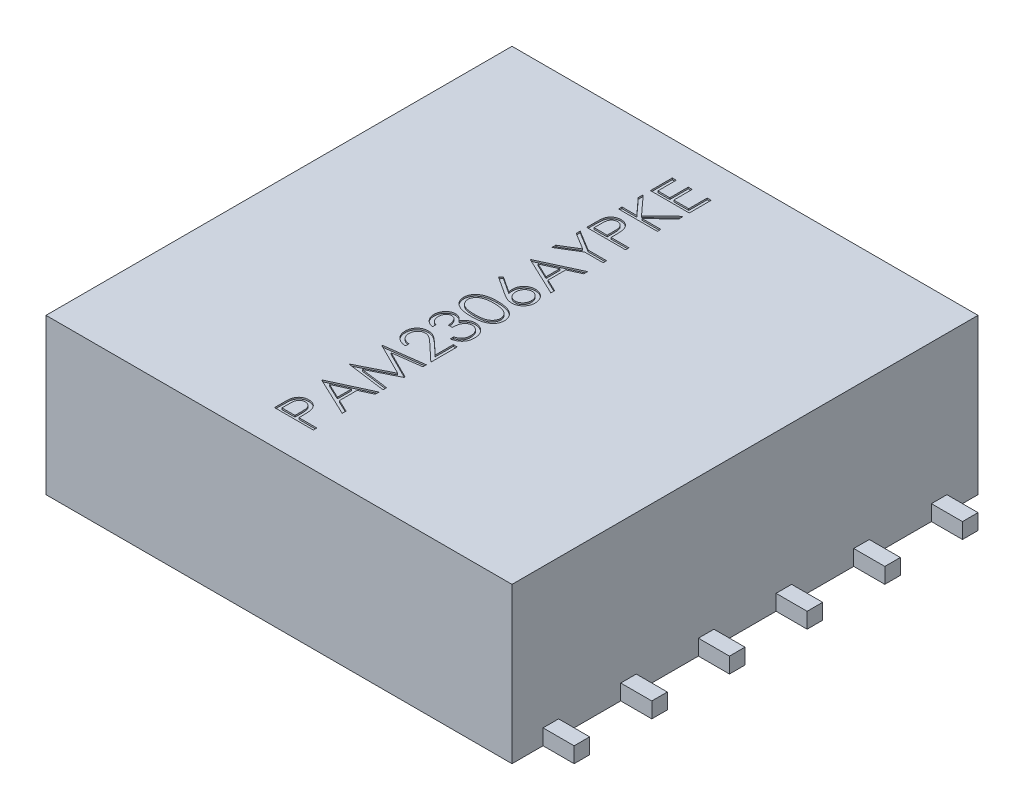
from build123d import *

# Parameters (mm, degrees)
BASES_W                = 3
BASES_H                = 3
BASE_DEPTH             = 1
SOLDERCONNECTIONS_W    = 0.2
SOLDERCONNECTIONS_H    = 0.1
SOLDERCONNECTION_DEPTH = 0.1
SC_LP_COUNT            = 6
SC_LP_PITCH            = 0.5
SC_CP_COUNT            = 2
SC_CP_COPY_1_SKETCH_W  = 0.2
SC_CP_COPY_1_SKETCH_H  = 0.1
SC_CP_COPY_1_DEPTH     = 0.1
SC_CP_COPY_2_SKETCH_W  = 0.2
SC_CP_COPY_2_SKETCH_H  = 0.1
SC_CP_COPY_2_DEPTH     = 0.1
SC_CP_COPY_3_SKETCH_W  = 0.2
SC_CP_COPY_3_SKETCH_H  = 0.1
SC_CP_COPY_3_DEPTH     = 0.1
SC_CP_COPY_4_SKETCH_W  = 0.2
SC_CP_COPY_4_SKETCH_H  = 0.1
SC_CP_COPY_4_DEPTH     = 0.1
SC_CP_COPY_5_SKETCH_W  = 0.2
SC_CP_COPY_5_SKETCH_H  = 0.1
SC_CP_COPY_5_DEPTH     = 0.1
PARTNO_DEPTH           = 0.01


with BuildPart() as part:
    # BaseS → Base (new body)
    with BuildSketch(Plane(origin=(0, 0, 0), x_dir=(1, 0, 0), z_dir=(0, 1, 0))):
        Rectangle(BASES_W, BASES_H)
    extrude(amount=BASE_DEPTH)

    # SolderConnectionS → SolderConnection (add)
    with BuildSketch(Plane(origin=(0, 0, 0), x_dir=(1, 0, 0), z_dir=(0, 1, 0))):
        with Locations((1.6, -1.25)):
            Rectangle(SOLDERCONNECTIONS_W, SOLDERCONNECTIONS_H)
    solderconnection = extrude(amount=SOLDERCONNECTION_DEPTH)

    # SC LP: SolderConnection ×6
    with Locations(*[(0, 0, -i * SC_LP_PITCH) for i in range(1, SC_LP_COUNT)]):
        add(solderconnection)

    # SC CP: SolderConnection ×2 about axis
    sc_cp_axis = Axis((0, 0.84, 0), (0, -1, 0))
    for i in range(1, SC_CP_COUNT):
        add(solderconnection.rotate(sc_cp_axis, i * 360 / SC_CP_COUNT))

    # SC CP copy 1 sketch → SC CP copy 1 (add)
    with BuildSketch(Plane(origin=(0, 0, 0.5), x_dir=(-1, 0, 0), z_dir=(0, 1, 0))):
        with Locations((1.6, -1.25)):
            Rectangle(SC_CP_COPY_1_SKETCH_W, SC_CP_COPY_1_SKETCH_H)
    extrude(amount=SC_CP_COPY_1_DEPTH)

    # SC CP copy 2 sketch → SC CP copy 2 (add)
    with BuildSketch(Plane(origin=(0, 0, 1), x_dir=(-1, 0, 0), z_dir=(0, 1, 0))):
        with Locations((1.6, -1.25)):
            Rectangle(SC_CP_COPY_2_SKETCH_W, SC_CP_COPY_2_SKETCH_H)
    extrude(amount=SC_CP_COPY_2_DEPTH)

    # SC CP copy 3 sketch → SC CP copy 3 (add)
    with BuildSketch(Plane(origin=(0, 0, 1.5), x_dir=(-1, 0, 0), z_dir=(0, 1, 0))):
        with Locations((1.6, -1.25)):
            Rectangle(SC_CP_COPY_3_SKETCH_W, SC_CP_COPY_3_SKETCH_H)
    extrude(amount=SC_CP_COPY_3_DEPTH)

    # SC CP copy 4 sketch → SC CP copy 4 (add)
    with BuildSketch(Plane(origin=(0, 0, 2), x_dir=(-1, 0, 0), z_dir=(0, 1, 0))):
        with Locations((1.6, -1.25)):
            Rectangle(SC_CP_COPY_4_SKETCH_W, SC_CP_COPY_4_SKETCH_H)
    extrude(amount=SC_CP_COPY_4_DEPTH)

    # SC CP copy 5 sketch → SC CP copy 5 (add)
    with BuildSketch(Plane(origin=(0, 0, 2.5), x_dir=(-1, 0, 0), z_dir=(0, 1, 0))):
        with Locations((1.6, -1.25)):
            Rectangle(SC_CP_COPY_5_SKETCH_W, SC_CP_COPY_5_SKETCH_H)
    extrude(amount=SC_CP_COPY_5_DEPTH)

    # PartNoS → PartNo (cut)
    # profile 1 of 12: a face of its own
    with BuildSketch(Plane(origin=(0, 1, 0), x_dir=(1, 0, 0), z_dir=(0, 1, 0))):
        with BuildLine():
            Line((-0.25, -1.278846154), (-0.25, -1.229817708))
            add(Edge.make_bspline(
                [(-0.25, -1.229817708), (-0.249996293, -1.226445501), (-0.249989191, -1.219984201), (-0.249773852, -1.21071884), (-0.249486231, -1.202303859), (-0.249087524, -1.194757404), (-0.248616339, -1.188056254), (-0.247955479, -1.182230732), (-0.247265458, -1.17723505), (-0.246563929, -1.174241732), (-0.24624399, -1.172876603)],
                knots=[0, 0, 0, 0, 1.415646017, 2.712440637, 3.8905458, 4.950247383, 5.884950622, 6.709939814, 7.411656543, 8, 8, 8, 8], degree=3))
            add(Edge.make_bspline(
                [(-0.24624399, -1.172876603), (-0.245770975, -1.171148508), (-0.244836092, -1.167733039), (-0.242963951, -1.162811318), (-0.240742802, -1.15812971), (-0.238216195, -1.15366732), (-0.23525976, -1.149505424), (-0.232070175, -1.145505281), (-0.228441316, -1.141808097), (-0.224487638, -1.138363795), (-0.220259285, -1.135180321), (-0.215679435, -1.132505628), (-0.210884821, -1.13016696), (-0.205810279, -1.128252173), (-0.200450883, -1.126828258), (-0.194844721, -1.125771145), (-0.188985488, -1.125097091), (-0.184981158, -1.125032752), (-0.182942708, -1.125)],
                knots=[0, 0, 0, 0, 0.999549623, 1.97554611, 2.93413192, 3.889860808, 4.833293765, 5.780583482, 6.742559327, 7.719844669, 8.705620613, 9.691528643, 10.674968152, 11.680406189, 12.713313868, 13.765869198, 14.862690416, 16, 16, 16, 16], degree=3))
            add(Edge.make_bspline(
                [(-0.182942708, -1.125), (-0.180887153, -1.125030102), (-0.17686532, -1.125088998), (-0.170981549, -1.125795875), (-0.165358807, -1.126748032), (-0.160009561, -1.128212107), (-0.154965577, -1.130129655), (-0.150149775, -1.132379088), (-0.145644084, -1.135092197), (-0.141432147, -1.138209685), (-0.13751001, -1.141677656), (-0.133906096, -1.145481437), (-0.130641501, -1.149605672), (-0.127708905, -1.154037254), (-0.125176313, -1.158819386), (-0.122907934, -1.16387954), (-0.121002859, -1.169261698), (-0.120000711, -1.172986164), (-0.119491186, -1.174879808)],
                knots=[0, 0, 0, 0, 1.121902311, 2.195077645, 3.232258892, 4.234102512, 5.217864754, 6.176164875, 7.132989551, 8.084763148, 9.034132444, 9.988522005, 10.94243251, 11.903244335, 12.886203696, 13.894208494, 14.929344452, 16, 16, 16, 16], degree=3))
            add(Edge.make_bspline(
                [(-0.119491186, -1.174879808), (-0.119158364, -1.176446064), (-0.118428966, -1.179878605), (-0.117609142, -1.185531302), (-0.116936797, -1.192116061), (-0.11630936, -1.199610477), (-0.115976896, -1.208032027), (-0.11558653, -1.217361396), (-0.115402338, -1.227630158), (-0.115390694, -1.2347923), (-0.115384615, -1.238531651)],
                knots=[0, 0, 0, 0, 0.601372724, 1.317943291, 2.144091499, 3.08771165, 4.142394186, 5.309582461, 6.595334295, 8, 8, 8, 8], degree=3))
            Line((-0.115384615, -1.238531651), (-0.115384615, -1.256410256))
            Line((-0.115384615, -1.256410256), (0, -1.256410256))
            Line((0, -1.256410256), (0, -1.278846154))
            Line((0, -1.278846154), (-0.25, -1.278846154))
        make_face()
        with BuildLine():
            Line((-0.224358974, -1.256410256), (-0.141025641, -1.256410256))
            Line((-0.141025641, -1.256410256), (-0.14047476, -1.212640224))
            add(Edge.make_bspline(
                [(-0.14047476, -1.212640224), (-0.140473583, -1.210503072), (-0.140471311, -1.206377343), (-0.140756937, -1.200417813), (-0.141082265, -1.1948879), (-0.141574306, -1.189808398), (-0.142219293, -1.185161486), (-0.1430214, -1.180987301), (-0.143893417, -1.177223412), (-0.145350342, -1.172893786), (-0.147590513, -1.168027143), (-0.150851581, -1.162710708), (-0.15507614, -1.158239981), (-0.159812763, -1.154378327), (-0.165067871, -1.151253538), (-0.170720098, -1.149049124), (-0.176685707, -1.147691737), (-0.180765362, -1.147522212), (-0.182842548, -1.147435897)],
                knots=[0, 0, 0, 0, 1.160746174, 2.240796558, 3.240300023, 4.169675897, 5.012224395, 5.787635701, 6.478238024, 7.109103438, 8.265591281, 9.382545711, 10.479929969, 11.588830844, 12.694575677, 13.785760505, 14.872603606, 16, 16, 16, 16], degree=3))
            add(Edge.make_bspline(
                [(-0.182842548, -1.147435897), (-0.18485244, -1.147526087), (-0.188847856, -1.147705374), (-0.194703511, -1.149037922), (-0.200291665, -1.151277209), (-0.205504452, -1.154381059), (-0.210230653, -1.158148997), (-0.214343278, -1.162524935), (-0.217627308, -1.167520067), (-0.219828603, -1.172127959), (-0.221117383, -1.176254269), (-0.222048223, -1.179820684), (-0.2226901, -1.183868148), (-0.223304297, -1.188358204), (-0.223800077, -1.193285151), (-0.224144365, -1.198680303), (-0.224343744, -1.204525695), (-0.224353775, -1.208583574), (-0.224358974, -1.210687099)],
                knots=[0, 0, 0, 0, 1.120540835, 2.227496496, 3.330685923, 4.466139262, 5.598993257, 6.692710361, 7.80064471, 8.921224235, 9.527843361, 10.209888745, 10.975318552, 11.811557897, 12.738105936, 13.73658638, 14.826690375, 16, 16, 16, 16], degree=3))
            Line((-0.224358974, -1.210687099), (-0.224358974, -1.256410256))
        make_face(mode=Mode.SUBTRACT)
    # profile 2 of 12: a face of its own
    with BuildSketch(Plane(origin=(0, 1, 0), x_dir=(1, 0, 0), z_dir=(0, 1, 0))):
        Polygon((-0.25, -0.971153846), (0, -0.855769231), (0, -0.880158253), (-0.080128205, -0.917117388), (-0.080128205, -1.030448718), (0, -1.068459535), (0, -1.092948718), (-0.25, -0.974358974), align=None)
        Polygon((-0.201272035, -0.973006811), (-0.105769231, -1.018279247), (-0.105769231, -0.928936298), align=None, mode=Mode.SUBTRACT)
    # profile 3 of 12: a face of its own
    with BuildSketch(Plane(origin=(0, 1, 0), x_dir=(1, 0, 0), z_dir=(0, 1, 0))):
        Polygon((0, -0.830128205), (-0.25, -0.797125401), (-0.25, -0.793920272), (-0.044871795, -0.690705128), (-0.25, -0.587740385), (-0.25, -0.584485176), (0, -0.551282051), (0, -0.573818109), (-0.179887821, -0.59775641), (0, -0.688000801), (0, -0.693058894), (-0.180288462, -0.783653846), (0, -0.807542067), align=None)
    # profile 4 of 12: a face of its own
    with BuildSketch(Plane(origin=(0, 1, 0), x_dir=(1, 0, 0), z_dir=(0, 1, 0))):
        with BuildLine():
            Line((-0.173076923, -0.490384615), (-0.173076923, -0.512820513))
            add(Edge.make_bspline(
                [(-0.173076923, -0.512820513), (-0.176053415, -0.512674288), (-0.181899166, -0.512387105), (-0.190422302, -0.511042227), (-0.198569074, -0.509117879), (-0.206274067, -0.506397061), (-0.213605411, -0.503018041), (-0.220533983, -0.498965896), (-0.227033354, -0.494166335), (-0.233043271, -0.488722997), (-0.238556669, -0.482810952), (-0.243317758, -0.476431956), (-0.247340449, -0.46972874), (-0.250703395, -0.46272164), (-0.253227669, -0.4553316), (-0.255100644, -0.447625681), (-0.256227526, -0.439570029), (-0.256348653, -0.434081456), (-0.256410256, -0.431290064)],
                knots=[0, 0, 0, 0, 1.10065271, 2.161652631, 3.183658789, 4.190468796, 5.17591951, 6.163126047, 7.15150782, 8.156236427, 9.156009102, 10.134482811, 11.092018607, 12.041330605, 13.001268258, 13.972401359, 14.968799086, 16, 16, 16, 16], degree=3))
            add(Edge.make_bspline(
                [(-0.256410256, -0.431290064), (-0.256346602, -0.42854858), (-0.256221523, -0.423161662), (-0.255131225, -0.415302819), (-0.25346044, -0.407803597), (-0.250984601, -0.400748987), (-0.247877964, -0.394066586), (-0.244014453, -0.387839136), (-0.239576879, -0.381916049), (-0.234342541, -0.37658802), (-0.22875749, -0.371693582), (-0.222792703, -0.367474873), (-0.216624929, -0.363841688), (-0.210205989, -0.360868039), (-0.20351498, -0.358613881), (-0.196616052, -0.356943766), (-0.189429585, -0.355989038), (-0.184564691, -0.355843317), (-0.182091346, -0.355769231)],
                knots=[0, 0, 0, 0, 1.111674182, 2.184400057, 3.212814286, 4.223731311, 5.211378316, 6.196328225, 7.191884489, 8.207283132, 9.220262353, 10.201199469, 11.166417575, 12.120932471, 13.06540007, 14.026332106, 14.996573967, 16, 16, 16, 16], degree=3))
            add(Edge.make_bspline(
                [(-0.182091346, -0.355769231), (-0.178609359, -0.35589018), (-0.17170649, -0.356129956), (-0.161562549, -0.358180955), (-0.151734532, -0.361384383), (-0.143824455, -0.365240996), (-0.137451237, -0.369132649), (-0.132201254, -0.372636087), (-0.126549921, -0.376760765), (-0.120474365, -0.381471444), (-0.114054149, -0.386849248), (-0.107158286, -0.392754463), (-0.099914283, -0.399339594), (-0.094963308, -0.403957353), (-0.092397837, -0.40635016)],
                knots=[0, 0, 0, 0, 1.184416499, 2.348048165, 3.509039915, 4.696071444, 5.333504901, 6.05069495, 6.844171097, 7.714965912, 8.667477798, 9.695072654, 10.805644396, 12, 12, 12, 12], degree=3))
            Line((-0.092397837, -0.40635016), (-0.025641026, -0.46890024))
            Line((-0.025641026, -0.46890024), (-0.025641026, -0.352564103))
            Line((-0.025641026, -0.352564103), (0, -0.352564103))
            Line((0, -0.352564103), (0, -0.522435897))
            Line((0, -0.522435897), (-0.103465545, -0.425480769))
            add(Edge.make_bspline(
                [(-0.103465545, -0.425480769), (-0.10592971, -0.423120206), (-0.110662866, -0.418586047), (-0.117573077, -0.412173006), (-0.123983759, -0.406413078), (-0.129882798, -0.401268978), (-0.135356481, -0.396852299), (-0.140227532, -0.392932854), (-0.144709992, -0.389792455), (-0.14990575, -0.386384212), (-0.156249487, -0.383083214), (-0.164001894, -0.380246617), (-0.171982412, -0.378516985), (-0.177375414, -0.378309497), (-0.180088141, -0.378205128)],
                knots=[0, 0, 0, 0, 1.329631726, 2.553950428, 3.673215718, 4.687767853, 5.603093632, 6.413772471, 7.123043292, 7.734684054, 8.834405432, 9.900288307, 10.943827018, 12, 12, 12, 12], degree=3))
            add(Edge.make_bspline(
                [(-0.180088141, -0.378205128), (-0.181793955, -0.378250538), (-0.185155787, -0.378340033), (-0.19008477, -0.379129869), (-0.1948394, -0.380323476), (-0.199434301, -0.382033852), (-0.203823276, -0.384291476), (-0.208011668, -0.387039575), (-0.212060879, -0.390210293), (-0.215857544, -0.393878241), (-0.219334773, -0.397907636), (-0.222415064, -0.402164368), (-0.224989287, -0.406667947), (-0.227099536, -0.411399384), (-0.228754921, -0.416345489), (-0.229901962, -0.421515828), (-0.23062214, -0.426896115), (-0.23071958, -0.430569936), (-0.230769231, -0.432441907)],
                knots=[0, 0, 0, 0, 0.991446411, 1.95395049, 2.89581595, 3.838931463, 4.798493298, 5.75982156, 6.748411868, 7.785213223, 8.824556874, 9.840280684, 10.836137867, 11.835679398, 12.848801643, 13.863922112, 14.911575587, 16, 16, 16, 16], degree=3))
            add(Edge.make_bspline(
                [(-0.230769231, -0.432441907), (-0.230720172, -0.434397457), (-0.23062383, -0.438237835), (-0.229894082, -0.443864391), (-0.228787784, -0.449268944), (-0.227030742, -0.454370853), (-0.22495471, -0.459280596), (-0.222317334, -0.463893357), (-0.219252645, -0.468285724), (-0.215699013, -0.47238545), (-0.211706251, -0.476129805), (-0.207305951, -0.47946597), (-0.202529793, -0.482361762), (-0.197397378, -0.484891842), (-0.191857607, -0.486945581), (-0.185931403, -0.48851516), (-0.179644145, -0.489757058), (-0.175302355, -0.490171955), (-0.173076923, -0.490384615)],
                knots=[0, 0, 0, 0, 1.030878251, 2.024474673, 2.987898669, 3.934362936, 4.864849709, 5.795128259, 6.730474222, 7.685293701, 8.650606017, 9.611896181, 10.591709709, 11.591680886, 12.625074257, 13.701333388, 14.821793024, 16, 16, 16, 16], degree=3))
        make_face()
    # profile 5 of 12: a face of its own
    with BuildSketch(Plane(origin=(0, 1, 0), x_dir=(1, 0, 0), z_dir=(0, 1, 0))):
        with BuildLine():
            Line((-0.192307692, -0.298076923), (-0.192307692, -0.320512821))
            add(Edge.make_bspline(
                [(-0.192307692, -0.320512821), (-0.194824298, -0.319904995), (-0.199744057, -0.318716747), (-0.206773147, -0.316238349), (-0.213424827, -0.313538402), (-0.219574547, -0.310296323), (-0.225345897, -0.306759984), (-0.230607977, -0.302708361), (-0.235494618, -0.298328381), (-0.239831278, -0.293483741), (-0.243758258, -0.288403123), (-0.247106477, -0.283014936), (-0.249986773, -0.277427586), (-0.252359647, -0.271602362), (-0.254147184, -0.265521921), (-0.255444099, -0.259241234), (-0.256286322, -0.252743841), (-0.256368519, -0.248333299), (-0.256410256, -0.24609375)],
                knots=[0, 0, 0, 0, 1.162005537, 2.271625781, 3.343758855, 4.383309926, 5.390229558, 6.379919256, 7.361854164, 8.333198761, 9.295911338, 10.242430842, 11.177959212, 12.116337295, 13.062827104, 14.020064771, 14.994644689, 16, 16, 16, 16], degree=3))
            add(Edge.make_bspline(
                [(-0.256410256, -0.24609375), (-0.25631174, -0.242830697), (-0.256116856, -0.236375768), (-0.254337253, -0.226892693), (-0.251521173, -0.21774792), (-0.247630192, -0.209041545), (-0.242831098, -0.200954514), (-0.237119331, -0.193759072), (-0.230605095, -0.18755275), (-0.223409912, -0.182346009), (-0.215720233, -0.178269223), (-0.207805936, -0.175263054), (-0.199685795, -0.173432934), (-0.194203133, -0.173195751), (-0.19145633, -0.173076923)],
                knots=[0, 0, 0, 0, 1.083050992, 2.142477498, 3.193116406, 4.255571735, 5.30263384, 6.308962982, 7.297363603, 8.282367274, 9.249857812, 10.179914175, 11.08814088, 12, 12, 12, 12], degree=3))
            add(Edge.make_bspline(
                [(-0.19145633, -0.173076923), (-0.188812988, -0.173160037), (-0.183640377, -0.173322677), (-0.176088841, -0.174703656), (-0.168971584, -0.177027675), (-0.162258644, -0.180246944), (-0.155992584, -0.184414197), (-0.150159306, -0.189462247), (-0.144732937, -0.195426723), (-0.141624404, -0.199946647), (-0.140024038, -0.202273638)],
                knots=[0, 0, 0, 0, 1.024540389, 2.004866551, 2.965041327, 3.920577974, 4.882998113, 5.874504559, 6.905732034, 8, 8, 8, 8], degree=3))
            add(Edge.make_bspline(
                [(-0.140024038, -0.202273638), (-0.138744539, -0.199610837), (-0.136205371, -0.194326508), (-0.131146552, -0.187196407), (-0.125449067, -0.180625086), (-0.120953185, -0.177003459), (-0.118689904, -0.175180288)],
                knots=[0, 0, 0, 0, 1.015663554, 2.015584519, 3.001021554, 4, 4, 4, 4], degree=3))
            add(Edge.make_bspline(
                [(-0.118689904, -0.175180288), (-0.117042922, -0.173977335), (-0.113775928, -0.171591129), (-0.108523326, -0.168645733), (-0.103212505, -0.165973654), (-0.097701119, -0.163891495), (-0.092053046, -0.162279076), (-0.08625859, -0.161126502), (-0.080313017, -0.160410492), (-0.076290697, -0.160307953), (-0.07426883, -0.16025641)],
                knots=[0, 0, 0, 0, 1.025084078, 2.033381695, 3.024893161, 4.013698104, 4.991890475, 5.976764909, 6.982997093, 8, 8, 8, 8], degree=3))
            add(Edge.make_bspline(
                [(-0.07426883, -0.16025641), (-0.070768154, -0.160384608), (-0.063783275, -0.160640401), (-0.053463384, -0.162926129), (-0.043376894, -0.166471012), (-0.033724651, -0.17149948), (-0.024702354, -0.17765549), (-0.016570203, -0.184898306), (-0.009689708, -0.193331474), (-0.003871225, -0.20264936), (0.000736552, -0.212787856), (0.004057671, -0.223587495), (0.006049675, -0.234985778), (0.006288694, -0.242780493), (0.006410256, -0.246744792)],
                knots=[0, 0, 0, 0, 0.955697303, 1.906897079, 2.875188111, 3.870982192, 4.871999088, 5.854111427, 6.836107184, 7.836239895, 8.848948182, 9.870701427, 10.917064451, 12, 12, 12, 12], degree=3))
            add(Edge.make_bspline(
                [(0.006410256, -0.246744792), (0.0063477, -0.249417431), (0.006224611, -0.254676293), (0.005398128, -0.262410367), (0.003847587, -0.269777259), (0.001897566, -0.276848503), (-0.000798555, -0.283517378), (-0.004012832, -0.289879809), (-0.007827689, -0.295907907), (-0.012249543, -0.301565873), (-0.017199147, -0.306847662), (-0.022758727, -0.311618713), (-0.028824524, -0.315931811), (-0.0354511, -0.319759552), (-0.042619894, -0.323118044), (-0.050359634, -0.325935014), (-0.058610317, -0.328394577), (-0.064358471, -0.329540343), (-0.067307692, -0.330128205)],
                knots=[0, 0, 0, 0, 1.048603596, 2.063302207, 3.045874044, 3.999447474, 4.937100059, 5.862643889, 6.7929026, 7.7308982, 8.676022965, 9.627908155, 10.600123445, 11.591992905, 12.626222643, 13.701663232, 14.820785756, 16, 16, 16, 16], degree=3))
            Line((-0.067307692, -0.330128205), (-0.067307692, -0.307692308))
            add(Edge.make_bspline(
                [(-0.067307692, -0.307692308), (-0.065382763, -0.307107787), (-0.061638608, -0.305970843), (-0.056250014, -0.304035536), (-0.051310153, -0.30183066), (-0.046782788, -0.299465334), (-0.04262333, -0.296981159), (-0.038941768, -0.294201522), (-0.035576397, -0.291332297), (-0.033680353, -0.289169486), (-0.032752404, -0.288110978)],
                knots=[0, 0, 0, 0, 1.198163088, 2.33053128, 3.407730985, 4.417276592, 5.372219308, 6.28897303, 7.162600585, 8, 8, 8, 8], degree=3))
            add(Edge.make_bspline(
                [(-0.032752404, -0.288110978), (-0.031673682, -0.286711066), (-0.029519568, -0.283915563), (-0.026762774, -0.279363036), (-0.024403023, -0.27455842), (-0.022484919, -0.269461649), (-0.021045121, -0.264072039), (-0.020008822, -0.258411452), (-0.019324704, -0.252470601), (-0.019262538, -0.248416086), (-0.019230769, -0.246344151)],
                knots=[0, 0, 0, 0, 0.946083416, 1.889246487, 2.84504177, 3.809995578, 4.801312957, 5.829064617, 6.89060985, 8, 8, 8, 8], degree=3))
            add(Edge.make_bspline(
                [(-0.019230769, -0.246344151), (-0.019274762, -0.244004615), (-0.019360787, -0.239429854), (-0.020151909, -0.232754507), (-0.021304082, -0.226403975), (-0.023083581, -0.220448766), (-0.025282213, -0.214810873), (-0.028042813, -0.209569326), (-0.031281722, -0.204655319), (-0.03496309, -0.20013179), (-0.038993197, -0.196064254), (-0.043208416, -0.19248286), (-0.047590976, -0.189438241), (-0.052165127, -0.186982271), (-0.056911929, -0.185042946), (-0.061844703, -0.183722718), (-0.066923079, -0.182804752), (-0.070375148, -0.182729994), (-0.072115385, -0.182692308)],
                knots=[0, 0, 0, 0, 1.217147791, 2.380027433, 3.494444702, 4.572153297, 5.609568379, 6.639424714, 7.649109417, 8.668170816, 9.669597737, 10.625200337, 11.543417969, 12.441394052, 13.322311151, 14.205496177, 15.095365482, 16, 16, 16, 16], degree=3))
            add(Edge.make_bspline(
                [(-0.072115385, -0.182692308), (-0.074444617, -0.182801845), (-0.079091492, -0.183020374), (-0.085930693, -0.184681828), (-0.092522592, -0.187439284), (-0.098781811, -0.191223944), (-0.104512184, -0.195943702), (-0.1096616, -0.201375414), (-0.11390661, -0.207666849), (-0.116842231, -0.213453053), (-0.118844775, -0.21857927), (-0.120178726, -0.222966052), (-0.121308265, -0.227877247), (-0.122359144, -0.233253412), (-0.123253525, -0.239135071), (-0.123999369, -0.245515817), (-0.124596158, -0.252396943), (-0.124862665, -0.257160597), (-0.125, -0.259615385)],
                knots=[0, 0, 0, 0, 1.070505987, 2.135685285, 3.216438728, 4.346150463, 5.486482244, 6.621737109, 7.7759408, 8.963942283, 9.59839197, 10.305095457, 11.070459627, 11.915156775, 12.823989992, 13.805807174, 14.869297358, 16, 16, 16, 16], degree=3))
            Line((-0.125, -0.259615385), (-0.150641026, -0.259615385))
            add(Edge.make_bspline(
                [(-0.150641026, -0.259615385), (-0.150701077, -0.256523562), (-0.150818661, -0.250469559), (-0.151955441, -0.241602792), (-0.153780419, -0.233160032), (-0.156387998, -0.225262646), (-0.159459411, -0.218078361), (-0.163008344, -0.21182038), (-0.167025163, -0.206653447), (-0.171432961, -0.202523581), (-0.176134685, -0.199384593), (-0.181065121, -0.197127124), (-0.186243817, -0.19578167), (-0.189779364, -0.195602753), (-0.19155649, -0.195512821)],
                knots=[0, 0, 0, 0, 1.322091412, 2.58874672, 3.817242262, 5.011895168, 6.140903042, 7.155122731, 8.080855046, 8.929742606, 9.727943956, 10.488587771, 11.240295418, 12, 12, 12, 12], degree=3))
            add(Edge.make_bspline(
                [(-0.19155649, -0.195512821), (-0.192862261, -0.195541773), (-0.195460029, -0.195599374), (-0.199267218, -0.196354663), (-0.202957854, -0.197437449), (-0.206489858, -0.199009525), (-0.209870458, -0.201046392), (-0.213136739, -0.203503254), (-0.216246497, -0.206450133), (-0.219215774, -0.209750669), (-0.221916995, -0.213405439), (-0.224281011, -0.21732919), (-0.226286426, -0.221506011), (-0.227945607, -0.225909148), (-0.229192325, -0.230559118), (-0.230087847, -0.235432363), (-0.23064765, -0.240538648), (-0.230728255, -0.24402234), (-0.230769231, -0.245793269)],
                knots=[0, 0, 0, 0, 0.884325644, 1.759323928, 2.622595547, 3.489424008, 4.37295195, 5.294616785, 6.255907374, 7.274251867, 8.302369084, 9.333474657, 10.37669385, 11.44084034, 12.520297356, 13.637342342, 14.798947025, 16, 16, 16, 16], degree=3))
            add(Edge.make_bspline(
                [(-0.230769231, -0.245793269), (-0.230669848, -0.248639817), (-0.23047573, -0.254199787), (-0.228775514, -0.262215138), (-0.226062794, -0.269666519), (-0.222824721, -0.275362138), (-0.219628262, -0.279568036), (-0.216836663, -0.282573532), (-0.213734318, -0.285524997), (-0.210130149, -0.288228259), (-0.206268235, -0.290962115), (-0.201952258, -0.293451012), (-0.197294801, -0.295869562), (-0.194002256, -0.297326886), (-0.192307692, -0.298076923)],
                knots=[0, 0, 0, 0, 1.472543308, 2.876219568, 4.221790263, 5.565193594, 6.249813518, 6.953379497, 7.687249741, 8.463570142, 9.283606569, 10.136032583, 11.040678096, 12, 12, 12, 12], degree=3))
        make_face()
    # profile 6 of 12: a face of its own
    with BuildSketch(Plane(origin=(0, 1, 0), x_dir=(1, 0, 0), z_dir=(0, 1, 0))):
        with BuildLine():
            add(Edge.make_bspline(
                [(-0.12489984, -0.137820513), (-0.128906796, -0.137797083), (-0.136690366, -0.13775157), (-0.148032126, -0.137245254), (-0.158672147, -0.136404158), (-0.168610937, -0.135251489), (-0.177851064, -0.133848776), (-0.186367831, -0.131976241), (-0.194200662, -0.129846757), (-0.201375088, -0.127378719), (-0.207987804, -0.124593898), (-0.214160953, -0.121562805), (-0.219885659, -0.118165583), (-0.225251634, -0.114594863), (-0.230176926, -0.110711639), (-0.234718282, -0.106599173), (-0.238837405, -0.102175216), (-0.242537115, -0.097482677), (-0.245781221, -0.092553358), (-0.248656339, -0.08752196), (-0.251024558, -0.082298583), (-0.252961827, -0.076951989), (-0.254543264, -0.07147091), (-0.255629549, -0.065856746), (-0.256311822, -0.060096481), (-0.256377134, -0.056208544), (-0.256410256, -0.054236779)],
                knots=[0, 0, 0, 0, 1.646148282, 3.197666765, 4.66315463, 6.030252048, 7.307778049, 8.501004361, 9.610818041, 10.641065266, 11.615491391, 12.557119604, 13.464013759, 14.348536654, 15.203310953, 16.038349431, 16.863300206, 17.683791446, 18.490318933, 19.285717724, 20.06220424, 20.843281102, 21.620494212, 22.403315558, 23.190242141, 24, 24, 24, 24], degree=3))
            add(Edge.make_bspline(
                [(-0.256410256, -0.054236779), (-0.256382667, -0.052247566), (-0.256327774, -0.048289733), (-0.255555123, -0.042459365), (-0.254557839, -0.036730553), (-0.252958361, -0.031190212), (-0.251044378, -0.025733587), (-0.248518907, -0.020496373), (-0.245772262, -0.015293668), (-0.242421585, -0.010361824), (-0.238718536, -0.005553487), (-0.234514629, -0.001046173), (-0.229926207, 0.003275337), (-0.224850936, 0.007247822), (-0.219366633, 0.011041535), (-0.213427325, 0.014512465), (-0.207046174, 0.017732799), (-0.200252763, 0.020763073), (-0.192865628, 0.023412967), (-0.184930845, 0.025768935), (-0.176376561, 0.027700049), (-0.167250429, 0.029297047), (-0.157507238, 0.030536621), (-0.147166728, 0.031438762), (-0.136222431, 0.031915465), (-0.128739725, 0.032005222), (-0.12489984, 0.032051282)],
                knots=[0, 0, 0, 0, 0.810910589, 1.61342667, 2.396193133, 3.181089899, 3.963115317, 4.752255436, 5.550715454, 6.36105385, 7.181178335, 8.024612154, 8.872680183, 9.750181803, 10.651284446, 11.591556747, 12.554036451, 13.566402641, 14.62422919, 15.753422176, 16.94128843, 18.199818041, 19.531985927, 20.947085226, 22.433341622, 24, 24, 24, 24], degree=3))
            add(Edge.make_bspline(
                [(-0.12489984, 0.032051282), (-0.121076737, 0.032004208), (-0.113610902, 0.031912282), (-0.102715336, 0.031448986), (-0.092430564, 0.030514586), (-0.082745621, 0.02936282), (-0.073656017, 0.027747973), (-0.065167675, 0.025802216), (-0.057250542, 0.023585315), (-0.049961343, 0.020894752), (-0.04317972, 0.01793501), (-0.03684549, 0.014718131), (-0.03090775, 0.011266789), (-0.025408982, 0.007529972), (-0.020354082, 0.003492145), (-0.015749922, -0.000826336), (-0.011519277, -0.005373005), (-0.007775431, -0.010209374), (-0.004399244, -0.015187155), (-0.001552925, -0.020390388), (0.000913244, -0.02568591), (0.002929565, -0.03112659), (0.004493245, -0.036704029), (0.00556819, -0.042436768), (0.006323794, -0.048290556), (0.006381336, -0.052247841), (0.006410256, -0.054236779)],
                knots=[0, 0, 0, 0, 1.561645053, 3.049612875, 4.452756685, 5.778837748, 7.032101753, 8.221335837, 9.334924186, 10.387562255, 11.392109817, 12.355697819, 13.287721948, 14.19548756, 15.068665045, 15.927346723, 16.771751757, 17.602390507, 18.423119567, 19.225778204, 20.022010933, 20.807278863, 21.593079439, 22.384715467, 23.188155646, 24, 24, 24, 24], degree=3))
            add(Edge.make_bspline(
                [(0.006410256, -0.054236779), (0.006376945, -0.056208501), (0.006311262, -0.060096353), (0.00563171, -0.065857241), (0.004539174, -0.071448844), (0.003009417, -0.076898755), (0.001136928, -0.082234934), (-0.001302619, -0.087384672), (-0.004112203, -0.092405208), (-0.007311845, -0.097283223), (-0.010977799, -0.101926772), (-0.015031936, -0.106363061), (-0.019578216, -0.110476541), (-0.024545065, -0.114326094), (-0.029919024, -0.117934563), (-0.0357037, -0.121302428), (-0.041908972, -0.124397086), (-0.048573948, -0.127229485), (-0.055799294, -0.129740723), (-0.063652092, -0.131950367), (-0.072212102, -0.133715142), (-0.081435863, -0.135211061), (-0.091342118, -0.136409761), (-0.10193445, -0.137244905), (-0.113192746, -0.137751186), (-0.120926264, -0.137796982), (-0.12489984, -0.137820513)],
                knots=[0, 0, 0, 0, 0.810927267, 1.598990287, 2.382942141, 3.152806972, 3.926217614, 4.706701772, 5.493896336, 6.292070767, 7.104102563, 7.925577746, 8.761822141, 9.623241997, 10.509042271, 11.423174113, 12.375371989, 13.360203808, 14.400680605, 15.520553799, 16.714061498, 17.994519714, 19.364400916, 20.818312473, 22.365209998, 24, 24, 24, 24], degree=3))
        make_face()
        with BuildLine():
            add(Edge.make_bspline(
                [(-0.125, -0.115384615), (-0.121660821, -0.115375896), (-0.115180129, -0.115358974), (-0.105779213, -0.114929695), (-0.096996246, -0.114332183), (-0.088834657, -0.113580477), (-0.081322969, -0.112454691), (-0.074429955, -0.111177419), (-0.068168372, -0.109645408), (-0.062483502, -0.107823826), (-0.057294845, -0.105748868), (-0.052464105, -0.103487355), (-0.047934029, -0.101036319), (-0.043715606, -0.098345519), (-0.039860404, -0.095361755), (-0.036270701, -0.092223356), (-0.033071343, -0.088788938), (-0.029233574, -0.084038882), (-0.025267986, -0.077767606), (-0.021814675, -0.069866175), (-0.019644504, -0.061746992), (-0.019368521, -0.056236189), (-0.019230769, -0.053485577)],
                knots=[0, 0, 0, 0, 1.459098681, 2.831824031, 4.11146945, 5.306290378, 6.412266529, 7.42953815, 8.369053297, 9.227277979, 10.03601793, 10.809473603, 11.557037441, 12.285528272, 12.993193355, 13.685654407, 14.36688038, 15.041354379, 16.352855396, 17.594313975, 18.799247529, 20, 20, 20, 20], degree=3))
            add(Edge.make_bspline(
                [(-0.019230769, -0.053485577), (-0.019351387, -0.050719042), (-0.019592196, -0.045195787), (-0.021693877, -0.037084062), (-0.025110543, -0.029274313), (-0.029014002, -0.023110942), (-0.032755195, -0.018434971), (-0.035941243, -0.015083478), (-0.039509717, -0.012007695), (-0.043359612, -0.009090382), (-0.047564805, -0.00641474), (-0.052104984, -0.003981657), (-0.056992784, -0.001761419), (-0.060404908, -0.000496487), (-0.062149439, 0.00015024)],
                knots=[0, 0, 0, 0, 1.353621445, 2.702441307, 4.075953605, 5.516772412, 6.261413105, 7.007624062, 7.778524365, 8.566925914, 9.372323995, 10.217594641, 11.088702136, 12, 12, 12, 12], degree=3))
            add(Edge.make_bspline(
                [(-0.062149439, 0.00015024), (-0.064380135, 0.000903938), (-0.068909404, 0.002434268), (-0.075935379, 0.004406537), (-0.083307005, 0.00595978), (-0.090980227, 0.007357163), (-0.099011635, 0.008310953), (-0.107376376, 0.009078654), (-0.116080759, 0.009530846), (-0.121994687, 0.0095869), (-0.125, 0.009615385)],
                knots=[0, 0, 0, 0, 0.884706709, 1.796334032, 2.740027952, 3.714592787, 4.726048262, 5.777819803, 6.87074269, 8, 8, 8, 8], degree=3))
            add(Edge.make_bspline(
                [(-0.125, 0.009615385), (-0.128004827, 0.009576085), (-0.13388291, 0.009499208), (-0.142491351, 0.009205351), (-0.15066762, 0.008446525), (-0.158446939, 0.00760373), (-0.165786247, 0.006361072), (-0.172746982, 0.005021228), (-0.179242915, 0.003221143), (-0.185375735, 0.001298296), (-0.191075806, -0.000902423), (-0.196369564, -0.003325058), (-0.201283053, -0.00591204), (-0.205801091, -0.0087232), (-0.209949887, -0.01171938), (-0.213633975, -0.015008006), (-0.217032567, -0.018380227), (-0.220842639, -0.023176236), (-0.224758117, -0.029404), (-0.228263359, -0.037206897), (-0.230337856, -0.045282559), (-0.230625543, -0.050753209), (-0.230769231, -0.053485577)],
                knots=[0, 0, 0, 0, 1.313483664, 2.569454835, 3.763100662, 4.901599063, 5.988328865, 7.015709358, 7.99797933, 8.932480776, 9.824041341, 10.666387587, 11.475829342, 12.24921787, 12.990555181, 13.709176526, 14.405678811, 15.080244297, 16.38186033, 17.610124501, 18.806354173, 20, 20, 20, 20], degree=3))
            add(Edge.make_bspline(
                [(-0.230769231, -0.053485577), (-0.230625185, -0.056251039), (-0.230336832, -0.061787002), (-0.228272953, -0.069948904), (-0.224768373, -0.077804515), (-0.220850183, -0.084052815), (-0.217047175, -0.088790561), (-0.213810377, -0.092152576), (-0.210306413, -0.095334501), (-0.20641701, -0.098241), (-0.202213451, -0.100915845), (-0.197741957, -0.103461604), (-0.192902191, -0.105692875), (-0.187717602, -0.107774495), (-0.18203242, -0.109599115), (-0.17574818, -0.111113621), (-0.168838705, -0.112492399), (-0.161272132, -0.113485344), (-0.153108801, -0.114359699), (-0.144303373, -0.114923136), (-0.134870176, -0.115360941), (-0.128355954, -0.115376566), (-0.125, -0.115384615)],
                knots=[0, 0, 0, 0, 1.207546505, 2.417292871, 3.651582144, 4.952510111, 5.626719005, 6.30238548, 6.989136872, 7.692112372, 8.420316868, 9.164734959, 9.937886623, 10.746308695, 11.604196049, 12.543341915, 13.568754172, 14.680483261, 15.875568977, 17.154711427, 18.534182925, 20, 20, 20, 20], degree=3))
        make_face(mode=Mode.SUBTRACT)
    # profile 7 of 12: a face of its own
    with BuildSketch(Plane(origin=(0, 1, 0), x_dir=(1, 0, 0), z_dir=(0, 1, 0))):
        with BuildLine():
            Line((-0.256410256, 0.169871795), (-0.242838542, 0.187149439))
            Line((-0.242838542, 0.187149439), (-0.141826923, 0.12109375))
            add(Edge.make_bspline(
                [(-0.141826923, 0.12109375), (-0.142527913, 0.125491627), (-0.143895273, 0.134070183), (-0.144120841, 0.142753462), (-0.144230769, 0.146985176)],
                knots=[0, 0, 0, 0, 1.025318673, 2, 2, 2, 2], degree=3))
            add(Edge.make_bspline(
                [(-0.144230769, 0.146985176), (-0.144162476, 0.149526069), (-0.144028041, 0.15452774), (-0.142993481, 0.161871083), (-0.141363116, 0.168927436), (-0.138986525, 0.17566755), (-0.135950645, 0.182115624), (-0.132312148, 0.188308638), (-0.127883195, 0.194130265), (-0.122935605, 0.19965514), (-0.117456165, 0.204672137), (-0.111640539, 0.20911048), (-0.105489189, 0.21285903), (-0.099003497, 0.215845522), (-0.092234233, 0.218232257), (-0.085154996, 0.219931322), (-0.077753838, 0.220947049), (-0.072719532, 0.221084185), (-0.07016226, 0.221153846)],
                knots=[0, 0, 0, 0, 1.043709831, 2.054511743, 3.041122595, 4.01515914, 4.98481438, 5.965901842, 6.960491961, 7.985277438, 9.0096037, 10.00832444, 10.987059228, 11.962929573, 12.936966118, 13.931840027, 14.949438142, 16, 16, 16, 16], degree=3))
            add(Edge.make_bspline(
                [(-0.07016226, 0.221153846), (-0.066663578, 0.221052443), (-0.059779002, 0.220852905), (-0.049753965, 0.218856248), (-0.040209012, 0.215776797), (-0.031309305, 0.211304764), (-0.022993206, 0.205855278), (-0.015648871, 0.199128059), (-0.009098894, 0.191456874), (-0.003624011, 0.182778313), (0.000847796, 0.173439783), (0.004059556, 0.163628858), (0.006036958, 0.153441223), (0.006284857, 0.146526606), (0.006410256, 0.143028846)],
                knots=[0, 0, 0, 0, 1.031403119, 2.029557249, 3.004870281, 3.983165322, 4.960181699, 5.929903783, 6.912123683, 7.928973898, 8.949315281, 9.960468141, 10.968302741, 12, 12, 12, 12], degree=3))
            add(Edge.make_bspline(
                [(0.006410256, 0.143028846), (0.006301409, 0.139664655), (0.006085802, 0.13300078), (0.004155126, 0.123200508), (0.001048088, 0.113766966), (-0.003322168, 0.104821246), (-0.008749111, 0.096520634), (-0.015236893, 0.08903515), (-0.022794527, 0.082565412), (-0.031256686, 0.07713278), (-0.040337183, 0.07280569), (-0.049821883, 0.069591061), (-0.059670965, 0.067703418), (-0.066348313, 0.067440246), (-0.069711538, 0.067307692)],
                knots=[0, 0, 0, 0, 1.012172929, 2.004937354, 2.995255351, 3.995689452, 4.993936421, 5.973737378, 6.968231049, 7.979117505, 8.993136101, 9.989812463, 10.987515067, 12, 12, 12, 12], degree=3))
            add(Edge.make_bspline(
                [(-0.069711538, 0.067307692), (-0.072286152, 0.067392081), (-0.07754302, 0.067564387), (-0.085504736, 0.068767487), (-0.093651242, 0.070700686), (-0.100562255, 0.072865704), (-0.106223793, 0.075153247), (-0.110788328, 0.077057), (-0.115485547, 0.079426571), (-0.120476521, 0.081953241), (-0.125632624, 0.084864446), (-0.131040029, 0.08802985), (-0.136612738, 0.091536968), (-0.140394466, 0.093995551), (-0.142327724, 0.095252404)],
                knots=[0, 0, 0, 0, 1.173818275, 2.396712641, 3.66331629, 4.989737886, 5.693666774, 6.447286557, 7.243889047, 8.091586357, 8.998013824, 9.943181721, 10.948533338, 12, 12, 12, 12], degree=3))
            Line((-0.142327724, 0.095252404), (-0.256410256, 0.169871795))
        make_face()
        with BuildLine():
            add(Edge.make_bspline(
                [(-0.118589744, 0.142277644), (-0.118534706, 0.140373013), (-0.1184272, 0.136652714), (-0.11778932, 0.131197637), (-0.116628306, 0.126018011), (-0.115018459, 0.121112334), (-0.113033705, 0.116450343), (-0.110487093, 0.112124425), (-0.10752087, 0.108045562), (-0.104140403, 0.104278925), (-0.100441742, 0.100863034), (-0.096479508, 0.097921577), (-0.092349954, 0.095384249), (-0.088018378, 0.093321265), (-0.083486488, 0.091714831), (-0.078775112, 0.090552813), (-0.073852662, 0.089906116), (-0.070514626, 0.089798528), (-0.068810096, 0.08974359)],
                knots=[0, 0, 0, 0, 1.129656352, 2.206547016, 3.251334079, 4.271920891, 5.265058649, 6.249872215, 7.241923875, 8.251504132, 9.246416584, 10.222533834, 11.173322129, 12.116503788, 13.062124155, 14.020151864, 14.989013135, 16, 16, 16, 16], degree=3))
            add(Edge.make_bspline(
                [(-0.068810096, 0.08974359), (-0.067121107, 0.089789914), (-0.063792747, 0.089881202), (-0.058907054, 0.090658428), (-0.054216185, 0.091900742), (-0.049737769, 0.093695348), (-0.045385832, 0.095876152), (-0.041296227, 0.098675382), (-0.037336481, 0.101888085), (-0.033690578, 0.105639209), (-0.03030587, 0.109695658), (-0.027335157, 0.114020409), (-0.024823111, 0.118548344), (-0.022741604, 0.123266424), (-0.021209317, 0.128232968), (-0.020036269, 0.133367334), (-0.019394947, 0.138739328), (-0.019286213, 0.142376264), (-0.019230769, 0.144230769)],
                knots=[0, 0, 0, 0, 0.989367052, 1.949669134, 2.891858276, 3.827522767, 4.772653562, 5.738670152, 6.725809442, 7.756636004, 8.798867547, 9.819240912, 10.826537776, 11.829883227, 12.835515726, 13.868058748, 14.912904531, 16, 16, 16, 16], degree=3))
            add(Edge.make_bspline(
                [(-0.019230769, 0.144230769), (-0.019286218, 0.146085271), (-0.01939496, 0.149722201), (-0.02003622, 0.155094239), (-0.021209495, 0.160228445), (-0.022740958, 0.165195569), (-0.024825519, 0.169911497), (-0.027319437, 0.174435475), (-0.030324085, 0.178719323), (-0.033684767, 0.182778412), (-0.037357314, 0.186513947), (-0.041260548, 0.189802209), (-0.045418556, 0.192513985), (-0.049720657, 0.194781256), (-0.05421886, 0.196555992), (-0.058906324, 0.197804422), (-0.063792937, 0.198579994), (-0.067121171, 0.198671509), (-0.068810096, 0.198717949)],
                knots=[0, 0, 0, 0, 1.087281468, 2.132306021, 3.165025708, 4.170830268, 5.174347389, 6.181816599, 7.194310624, 8.23672049, 9.267723423, 10.261267456, 11.222032883, 12.171822355, 13.107646935, 14.049997283, 15.01046367, 16, 16, 16, 16], degree=3))
            add(Edge.make_bspline(
                [(-0.068810096, 0.198717949), (-0.07051685, 0.198678642), (-0.073866652, 0.198601496), (-0.07877291, 0.197728928), (-0.083510426, 0.196518759), (-0.08804942, 0.194691399), (-0.092371995, 0.192317363), (-0.096499933, 0.189425678), (-0.100465087, 0.186080545), (-0.104147641, 0.182216237), (-0.107517205, 0.178010547), (-0.110483013, 0.173535239), (-0.113014639, 0.168871919), (-0.115012293, 0.163954896), (-0.116621625, 0.15885033), (-0.117785181, 0.153522971), (-0.118425538, 0.147969032), (-0.118534311, 0.144198937), (-0.118589744, 0.142277644)],
                knots=[0, 0, 0, 0, 0.978259475, 1.920005202, 2.851759169, 3.7803069, 4.719124913, 5.675758531, 6.668034766, 7.691045932, 8.733780038, 9.756656648, 10.768121246, 11.773215211, 12.79725739, 13.836288844, 14.897342417, 16, 16, 16, 16], degree=3))
        make_face(mode=Mode.SUBTRACT)
    # profile 8 of 12: a face of its own
    with BuildSketch(Plane(origin=(0, 1, 0), x_dir=(1, 0, 0), z_dir=(0, 1, 0))):
        Polygon((-0.25, 0.371794872), (0, 0.487179487), (0, 0.462790465), (-0.080128205, 0.42583133), (-0.080128205, 0.3125), (0, 0.274489183), (0, 0.25), (-0.25, 0.368589744), align=None)
        Polygon((-0.201272035, 0.369941907), (-0.105769231, 0.324669471), (-0.105769231, 0.41401242), align=None, mode=Mode.SUBTRACT)
    # profile 9 of 12: a face of its own
    with BuildSketch(Plane(origin=(0, 1, 0), x_dir=(1, 0, 0), z_dir=(0, 1, 0))):
        Polygon((-0.25, 0.506410256), (-0.25, 0.532101362), (-0.142578125, 0.59780649), (-0.25, 0.663411458), (-0.25, 0.689102564), (-0.118840144, 0.608974359), (0, 0.608974359), (0, 0.586538462), (-0.118840144, 0.586538462), align=None)
    # profile 10 of 12: a face of its own
    with BuildSketch(Plane(origin=(0, 1, 0), x_dir=(1, 0, 0), z_dir=(0, 1, 0))):
        with BuildLine():
            Line((-0.25, 0.730769231), (-0.25, 0.779797676))
            add(Edge.make_bspline(
                [(-0.25, 0.779797676), (-0.249996293, 0.783169884), (-0.249989191, 0.789631183), (-0.249773852, 0.798896544), (-0.249486231, 0.807311525), (-0.249087524, 0.814857981), (-0.248616339, 0.821559131), (-0.247955479, 0.827384652), (-0.247265458, 0.832380335), (-0.246563929, 0.835373653), (-0.24624399, 0.836738782)],
                knots=[0, 0, 0, 0, 1.415646017, 2.712440637, 3.8905458, 4.950247383, 5.884950622, 6.709939814, 7.411656543, 8, 8, 8, 8], degree=3))
            add(Edge.make_bspline(
                [(-0.24624399, 0.836738782), (-0.245770975, 0.838466877), (-0.244836092, 0.841882345), (-0.242963951, 0.846804066), (-0.240742802, 0.851485674), (-0.238216195, 0.855948064), (-0.23525976, 0.860109961), (-0.232070175, 0.864110104), (-0.228441316, 0.867807287), (-0.224487638, 0.87125159), (-0.220259285, 0.874435063), (-0.215679435, 0.877109756), (-0.210884821, 0.879448425), (-0.205810279, 0.881363211), (-0.200450883, 0.882787126), (-0.194844721, 0.88384424), (-0.188985488, 0.884518294), (-0.184981158, 0.884582632), (-0.182942708, 0.884615385)],
                knots=[0, 0, 0, 0, 0.999549623, 1.97554611, 2.93413192, 3.889860808, 4.833293765, 5.780583482, 6.742559327, 7.719844669, 8.705620613, 9.691528643, 10.674968152, 11.680406189, 12.713313868, 13.765869198, 14.862690416, 16, 16, 16, 16], degree=3))
            add(Edge.make_bspline(
                [(-0.182942708, 0.884615385), (-0.180887153, 0.884585283), (-0.17686532, 0.884526387), (-0.170981549, 0.883819509), (-0.165358807, 0.882867353), (-0.160009561, 0.881403277), (-0.154965577, 0.879485729), (-0.150149775, 0.877236297), (-0.145644084, 0.874523188), (-0.141432147, 0.8714057), (-0.13751001, 0.867937729), (-0.133906096, 0.864133948), (-0.130641501, 0.860009712), (-0.127708905, 0.85557813), (-0.125176313, 0.850795998), (-0.122907934, 0.845735845), (-0.121002859, 0.840353686), (-0.120000711, 0.836629221), (-0.119491186, 0.834735577)],
                knots=[0, 0, 0, 0, 1.121902311, 2.195077645, 3.232258892, 4.234102512, 5.217864754, 6.176164875, 7.132989551, 8.084763148, 9.034132444, 9.988522005, 10.94243251, 11.903244335, 12.886203696, 13.894208494, 14.929344452, 16, 16, 16, 16], degree=3))
            add(Edge.make_bspline(
                [(-0.119491186, 0.834735577), (-0.119158364, 0.833169321), (-0.118428966, 0.82973678), (-0.117609142, 0.824084083), (-0.116936797, 0.817499324), (-0.11630936, 0.810004908), (-0.115976896, 0.801583358), (-0.11558653, 0.792253988), (-0.115402338, 0.781985226), (-0.115390694, 0.774823085), (-0.115384615, 0.771083734)],
                knots=[0, 0, 0, 0, 0.601372724, 1.317943291, 2.144091499, 3.08771165, 4.142394186, 5.309582461, 6.595334295, 8, 8, 8, 8], degree=3))
            Line((-0.115384615, 0.771083734), (-0.115384615, 0.753205128))
            Line((-0.115384615, 0.753205128), (0, 0.753205128))
            Line((0, 0.753205128), (0, 0.730769231))
            Line((0, 0.730769231), (-0.25, 0.730769231))
        make_face()
        with BuildLine():
            Line((-0.224358974, 0.753205128), (-0.141025641, 0.753205128))
            Line((-0.141025641, 0.753205128), (-0.14047476, 0.79697516))
            add(Edge.make_bspline(
                [(-0.14047476, 0.79697516), (-0.140473583, 0.799112313), (-0.140471311, 0.803238042), (-0.140756937, 0.809197572), (-0.141082265, 0.814727485), (-0.141574306, 0.819806986), (-0.142219293, 0.824453898), (-0.1430214, 0.828628083), (-0.143893417, 0.832391973), (-0.145350342, 0.836721599), (-0.147590513, 0.841588241), (-0.150851581, 0.846904677), (-0.15507614, 0.851375403), (-0.159812763, 0.855237058), (-0.165067871, 0.858361847), (-0.170720098, 0.860566261), (-0.176685707, 0.861923648), (-0.180765362, 0.862093172), (-0.182842548, 0.862179487)],
                knots=[0, 0, 0, 0, 1.160746174, 2.240796558, 3.240300023, 4.169675897, 5.012224395, 5.787635701, 6.478238024, 7.109103438, 8.265591281, 9.382545711, 10.479929969, 11.588830844, 12.694575677, 13.785760505, 14.872603606, 16, 16, 16, 16], degree=3))
            add(Edge.make_bspline(
                [(-0.182842548, 0.862179487), (-0.18485244, 0.862089297), (-0.188847856, 0.861910011), (-0.194703511, 0.860577462), (-0.200291665, 0.858338175), (-0.205504452, 0.855234326), (-0.210230653, 0.851466388), (-0.214343278, 0.84709045), (-0.217627308, 0.842095317), (-0.219828603, 0.837487426), (-0.221117383, 0.833361115), (-0.222048223, 0.8297947), (-0.2226901, 0.825747237), (-0.223304297, 0.821257181), (-0.223800077, 0.816330234), (-0.224144365, 0.810935081), (-0.224343744, 0.80508969), (-0.224353775, 0.801031811), (-0.224358974, 0.798928285)],
                knots=[0, 0, 0, 0, 1.120540835, 2.227496496, 3.330685923, 4.466139262, 5.598993257, 6.692710361, 7.80064471, 8.921224235, 9.527843361, 10.209888745, 10.975318552, 11.811557897, 12.738105936, 13.73658638, 14.826690375, 16, 16, 16, 16], degree=3))
            Line((-0.224358974, 0.798928285), (-0.224358974, 0.753205128))
        make_face(mode=Mode.SUBTRACT)
    # profile 11 of 12: a face of its own
    with BuildSketch(Plane(origin=(0, 1, 0), x_dir=(1, 0, 0), z_dir=(0, 1, 0))):
        Polygon((-0.25, 0.935897436), (-0.25, 0.958333333), (-0.154797676, 0.958333333), (-0.25, 1.06255008), (-0.25, 1.094551282), (-0.137820513, 0.971704728), (0, 1.104166667), (0, 1.07426883), (-0.120643029, 0.958333333), (0, 0.958333333), (0, 0.935897436), align=None)
    # profile 12 of 12: a face of its own
    with BuildSketch(Plane(origin=(0, 1, 0), x_dir=(1, 0, 0), z_dir=(0, 1, 0))):
        Polygon((-0.25, 1.141025641), (-0.25, 1.282051282), (-0.224358974, 1.282051282), (-0.224358974, 1.163461538), (-0.147435897, 1.163461538), (-0.147435897, 1.282051282), (-0.121794872, 1.282051282), (-0.121794872, 1.163461538), (-0.025641026, 1.163461538), (-0.025641026, 1.282051282), (0, 1.282051282), (0, 1.141025641), align=None)
    extrude(amount=-PARTNO_DEPTH, mode=Mode.SUBTRACT)


solid = part.part
